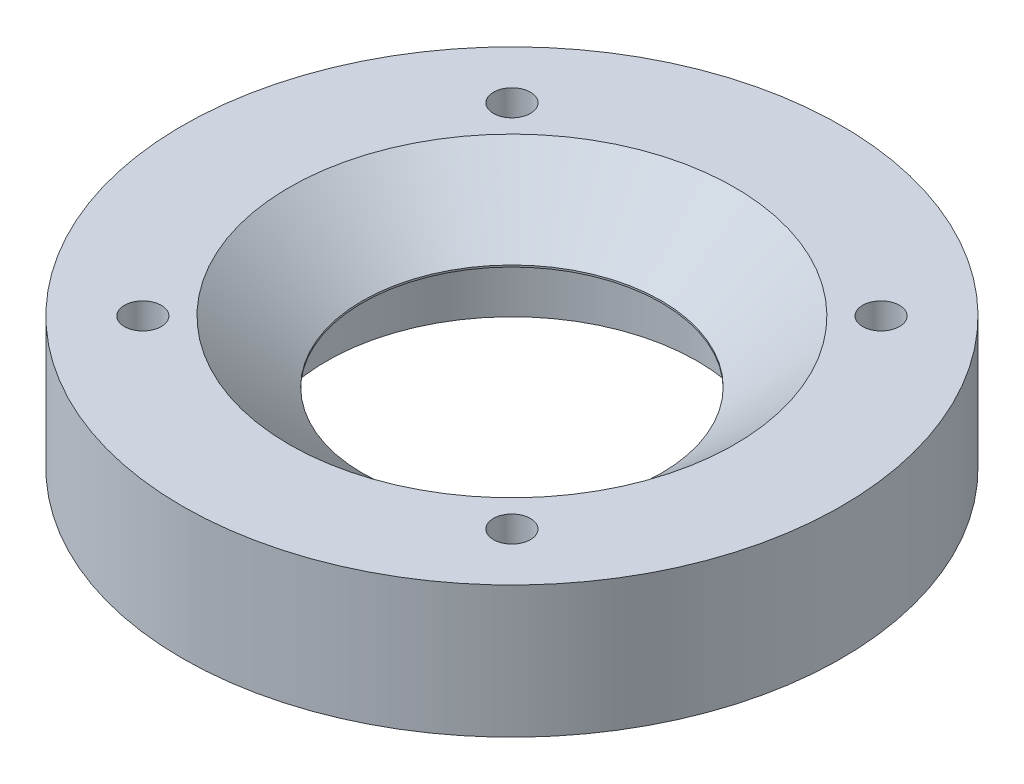
from build123d import *

# Parameters (mm, degrees)
SKETCH1_R           = 37.5
BOSS_EXTRUDE1_DEPTH = 15
SKETCH2_R           = 21.1
CUT_EXTRUDE1_DEPTH  = 7.8
SKETCH3_R           = 17
CUT_EXTRUDE2_DEPTH  = 8.2
SKETCH4_R           = 2.1
CUT_EXTRUDE3_DEPTH  = 16
CHAMFER1_SIZE       = 7
CHAMFER1_SIZE2      = 8.342275148


with BuildPart() as part:
    # Sketch1 → Boss-Extrude1 (new body)
    with BuildSketch(Plane(origin=(0, 0, 0), x_dir=(1, 0, 0), z_dir=(0, 1, 0))):
        with Locations(Location((0, 0, 0), (0, 0, 270))):  # turned: the seam where the file's is
            Circle(SKETCH1_R)
    extrude(amount=BOSS_EXTRUDE1_DEPTH)

    # Sketch2 → Cut-Extrude1 (cut)
    with BuildSketch(Plane.XZ):
        with Locations(Location((0, 0, 0), (0, 0, 270))):  # turned: the seam where the file's is
            Circle(SKETCH2_R)
    extrude(amount=-CUT_EXTRUDE1_DEPTH, mode=Mode.SUBTRACT)

    # Sketch3 → Cut-Extrude2 (cut, through all)
    with BuildSketch(Plane.XZ.offset(-7.8)):
        with Locations(Location((0, 0, 0), (0, 0, 270))):  # turned: the seam where the file's is
            Circle(SKETCH3_R)
    extrude(amount=-CUT_EXTRUDE2_DEPTH, mode=Mode.SUBTRACT)

    # Sketch4 → Cut-Extrude3 (cut, through all)
    with BuildSketch(Plane(origin=(0, 15, 0), x_dir=(1, 0, 0), z_dir=(0, 1, 0))):
        with Locations(Location((-21, -21, 0), (0, 0, 270))):  # turned: the seam where the file's is
            Circle(SKETCH4_R)
        with Locations(Location((-21, 21, 0), (0, 0, 270))):  # turned: the seam where the file's is
            Circle(SKETCH4_R)
        with Locations(Location((21, 21, 0), (0, 0, 270))):  # turned: the seam where the file's is
            Circle(SKETCH4_R)
        with Locations(Location((21, -21, 0), (0, 0, 270))):  # turned: the seam where the file's is
            Circle(SKETCH4_R)
    extrude(amount=-CUT_EXTRUDE3_DEPTH, mode=Mode.SUBTRACT)

    # Chamfer1
    chamfer1_edges = [part.edges().sort_by_distance(p)[0] for p in [
        (0, 15, 17),
    ]]
    chamfer1_side = [part.faces().sort_by_distance(p)[0] for p in [
        (0, 11.4, 17),
    ]]
    chamfer(chamfer1_edges, length=CHAMFER1_SIZE, length2=CHAMFER1_SIZE2, reference=chamfer1_side[0])


solid = part.part
